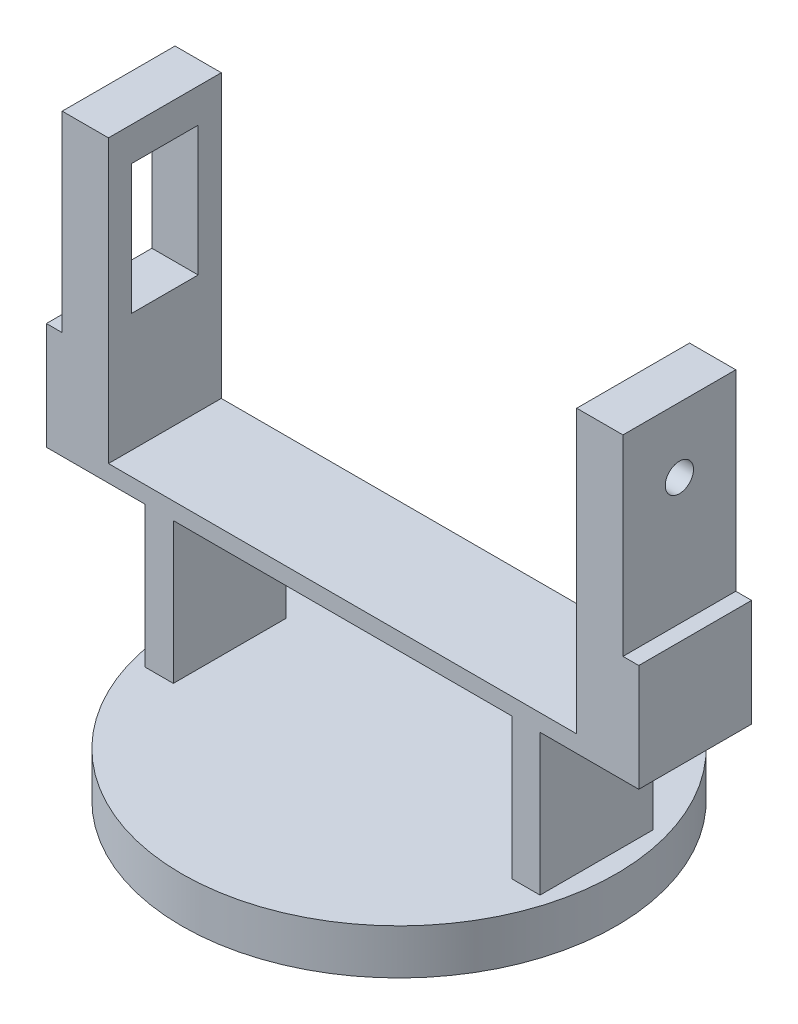
from build123d import *

# Parameters (mm, degrees)
SKETCH1_R           = 38.5
SKETCH1_R_2         = 28.5
BOSS_EXTRUDE1_DEPTH = 3
SKETCH3_R           = 38.5
BOSS_EXTRUDE2_DEPTH = 5
SKETCH4_W           = 5
SKETCH4_H           = 20
BOSS_EXTRUDE3_DEPTH = 25
SKETCH5_W           = 105
SKETCH5_H           = 20
BOSS_EXTRUDE4_DEPTH = 3
SKETCH6_W           = 2.8
SKETCH6_H           = 20
BOSS_EXTRUDE5_DEPTH = 16
SKETCH7_W           = 8.2
SKETCH7_H           = 20
BOSS_EXTRUDE6_DEPTH = 50
SKETCH8_W           = 11.8
SKETCH8_H           = 23
CUT_EXTRUDE1_DEPTH  = 50
SKETCH9_R           = 2.5
CUT_EXTRUDE2_DEPTH  = 50
SKETCH10_R          = 0.5
CUT_EXTRUDE3_DEPTH  = 1


with BuildPart() as part:
    # Sketch1 → Boss-Extrude1 (new body)
    with BuildSketch(Plane(origin=(0, 0, 0), x_dir=(1, 0, 0), z_dir=(0, 1, 0))):
        Circle(SKETCH1_R)
        Circle(SKETCH1_R_2, mode=Mode.SUBTRACT)
    extrude(amount=BOSS_EXTRUDE1_DEPTH)

    # Sketch3 → Boss-Extrude2 (add)
    with BuildSketch(Plane(origin=(0, 3, 0), x_dir=(1, 0, 0), z_dir=(0, 1, 0))):
        Circle(SKETCH3_R)
    extrude(amount=BOSS_EXTRUDE2_DEPTH)

    # Sketch4 → Boss-Extrude3 (add)
    with BuildSketch(Plane(origin=(0, 8, 0), x_dir=(1, 0, 0), z_dir=(0, 1, 0))):
        with Locations((-32.5, 0)):
            Rectangle(SKETCH4_W, SKETCH4_H)
        with Locations((32.5, 0)):
            Rectangle(SKETCH4_W, SKETCH4_H)
    extrude(amount=BOSS_EXTRUDE3_DEPTH)

    # Sketch5 → Boss-Extrude4 (add)
    with BuildSketch(Plane(origin=(0, 33, 0), x_dir=(1, 0, 0), z_dir=(0, 1, 0))):
        Rectangle(SKETCH5_W, SKETCH5_H)
    extrude(amount=BOSS_EXTRUDE4_DEPTH)

    # Sketch6 → Boss-Extrude5 (add)
    with BuildSketch(Plane(origin=(0, 36, 0), x_dir=(1, 0, 0), z_dir=(0, 1, 0))):
        with Locations((-51.1, 0)):
            Rectangle(SKETCH6_W, SKETCH6_H)
        with Locations((51.1, 0)):
            Rectangle(SKETCH6_W, SKETCH6_H)
    extrude(amount=BOSS_EXTRUDE5_DEPTH)

    # Sketch7 → Boss-Extrude6 (add)
    with BuildSketch(Plane(origin=(0, 36, 0), x_dir=(1, 0, 0), z_dir=(0, 1, 0))):
        with Locations((-45.6, 0)):
            Rectangle(SKETCH7_W, SKETCH7_H)
        with Locations((45.6, 0)):
            Rectangle(SKETCH7_W, SKETCH7_H)
    extrude(amount=BOSS_EXTRUDE6_DEPTH)

    # Sketch8 → Cut-Extrude1 (cut)
    with BuildSketch(Plane.ZY.offset(49.7)):
        with Locations((0, 68.5)):
            Rectangle(SKETCH8_W, SKETCH8_H)
    extrude(amount=-CUT_EXTRUDE1_DEPTH, mode=Mode.SUBTRACT)

    # Sketch9 → Cut-Extrude2 (cut)
    with BuildSketch(Plane.ZY.offset(-41.5)):
        with Locations((0, 74.47)):
            Circle(SKETCH9_R)
    extrude(amount=-CUT_EXTRUDE2_DEPTH, mode=Mode.SUBTRACT)

    # Sketch10 → Cut-Extrude3 (cut)
    with BuildSketch(Plane.XZ.offset(-3)):
        with BuildLine():
            Line((2, 7.5), (2, 2.88735269))
            Line((2, 2.88735269), (17.117647059, 1.996536794))
            ThreePointArc((17.117647059, 1.996536794), (19, 0), (17.117647059, -1.996536794))
            Line((17.117647059, -1.996536794), (2, -2.88735269))
            Line((2, -2.88735269), (2, -7.5))
            ThreePointArc((2, -7.5), (0, -9.5), (-2, -7.5))
            Line((-2, -7.5), (-2, -2.88735269))
            Line((-2, -2.88735269), (-17.117647059, -1.996536794))
            ThreePointArc((-17.117647059, -1.996536794), (-19, 0), (-17.117647059, 1.996536794))
            Line((-17.117647059, 1.996536794), (-2, 2.88735269))
            Line((-2, 2.88735269), (-2, 7.5))
            ThreePointArc((-2, 7.5), (0, 9.5), (2, 7.5))
        make_face()
        with Locations((-17, 0)):
            Circle(SKETCH10_R, mode=Mode.SUBTRACT)
        with Locations((17, 0)):
            Circle(SKETCH10_R, mode=Mode.SUBTRACT)
        with Locations((0, 7.5)):
            Circle(SKETCH10_R, mode=Mode.SUBTRACT)
        with Locations((0, -7.5)):
            Circle(SKETCH10_R, mode=Mode.SUBTRACT)
    extrude(amount=-CUT_EXTRUDE3_DEPTH, mode=Mode.SUBTRACT)


solid = part.part
